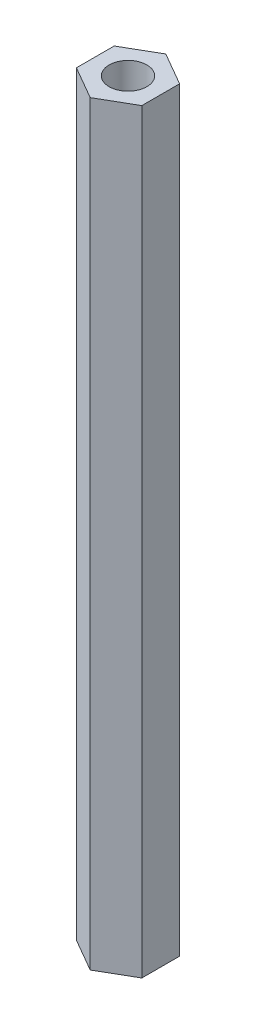
from build123d import *

# Parameters (mm, degrees)
ESQUISSE1_R      = 2.5
EXTRUSION1_DEPTH = 100


with BuildPart() as part:
    # Esquisse1 → Extrusion1 (new body)
    with BuildSketch(Plane(origin=(0, 0, 0), x_dir=(1, 0, 0), z_dir=(0, 1, 0))):
        Polygon((0, 5), (-4.330127019, 2.5), (-4.330127019, -2.5), (0, -5), (4.330127019, -2.5), (4.330127019, 2.5), align=None)
        Circle(ESQUISSE1_R, mode=Mode.SUBTRACT)
    extrude(amount=EXTRUSION1_DEPTH)


solid = part.part
